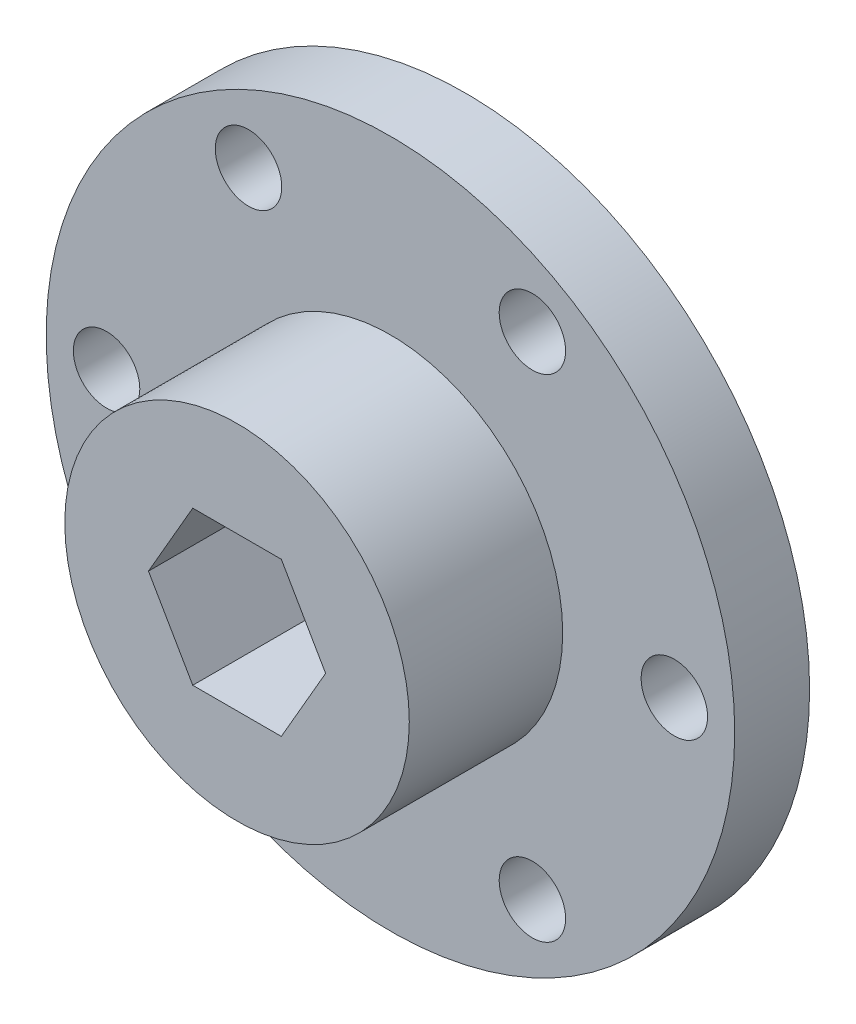
from build123d import *

# Parameters (mm, degrees)
SKETCH1_R           = 28.5
BOSS_EXTRUDE1_DEPTH = 6.2
SKETCH2_R           = 14.26
BOSS_EXTRUDE2_DEPTH = 12.7
SKETCH3_R           = 2.75
CUT_EXTRUDE1_DEPTH  = 19.9


with BuildPart() as part:
    # Sketch1 → Boss-Extrude1 (new body)
    with BuildSketch(Plane.XY):
        Circle(SKETCH1_R)
        Polygon((7.332348419, 0), (3.666174209, 6.35), (-3.666174209, 6.35), (-7.332348419, 0), (-3.666174209, -6.35), (3.666174209, -6.35), align=None, mode=Mode.SUBTRACT)
    extrude(amount=BOSS_EXTRUDE1_DEPTH)

    # Sketch2 → Boss-Extrude2 (add)
    with BuildSketch(Plane.XY.offset(6.2)):
        Circle(SKETCH2_R)
        Polygon((3.666174209, -6.35), (7.332348419, 0), (3.666174209, 6.35), (-3.666174209, 6.35), (-7.332348419, 0), (-3.666174209, -6.35), align=None, mode=Mode.SUBTRACT)
    extrude(amount=BOSS_EXTRUDE2_DEPTH)

    # Sketch3 → Cut-Extrude1 (cut, through all)
    with BuildSketch(Plane(origin=(0, 0, 0), x_dir=(-1, 0, 0), z_dir=(0, 0, -1))):
        with Locations((-11.75, 20.351596989)):
            Circle(SKETCH3_R)
        with Locations((11.75, 20.351596989)):
            Circle(SKETCH3_R)
        with Locations((23.5, 0)):
            Circle(SKETCH3_R)
        with Locations((11.75, -20.351596989)):
            Circle(SKETCH3_R)
        with Locations((-11.75, -20.351596989)):
            Circle(SKETCH3_R)
        with Locations((-23.5, 0)):
            Circle(SKETCH3_R)
    extrude(amount=-CUT_EXTRUDE1_DEPTH, mode=Mode.SUBTRACT)


solid = part.part
